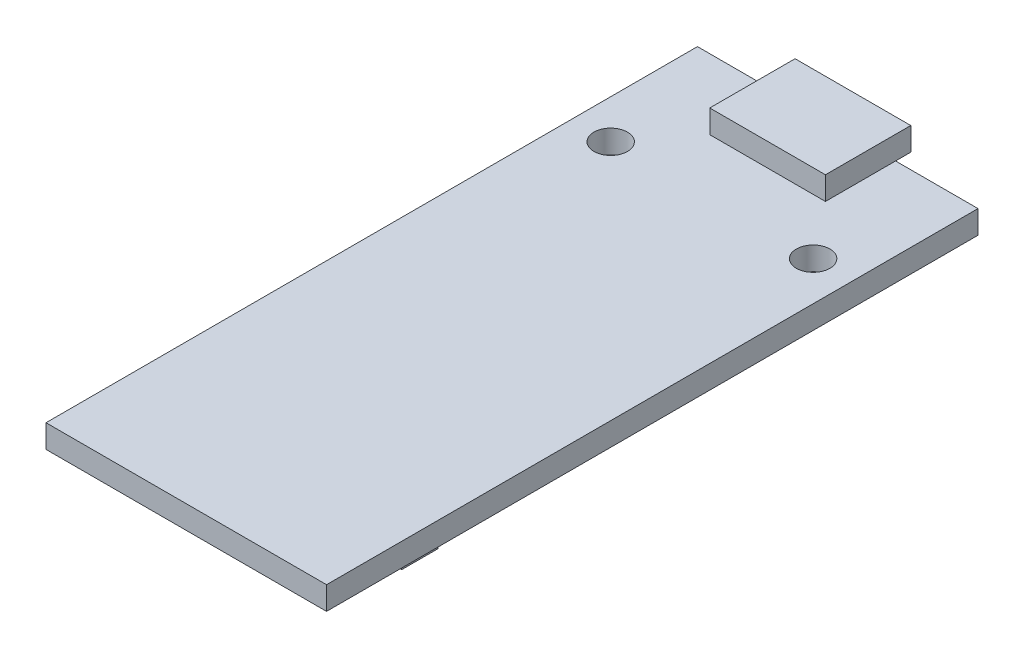
from build123d import *

# Parameters (mm, degrees)
SKETCH1_W           = 19.4
SKETCH1_H           = 45.05
BOSS_EXTRUDE1_DEPTH = 1.6
SKETCH2_W           = 8
SKETCH2_H           = 5.9
BOSS_EXTRUDE2_DEPTH = 1.6
SKETCH3_R           = 1.16
CUT_EXTRUDE3_DEPTH  = 4.2
SKETCH4_W           = 7.25
SKETCH4_H           = 2.5
SKETCH4_W_2         = 16.4
BOSS_EXTRUDE3_DEPTH = 1.6


with BuildPart() as part:
    # Sketch1 → Boss-Extrude1 (new body)
    with BuildSketch(Plane(origin=(0, 0, 0), x_dir=(1, 0, 0), z_dir=(0, 1, 0))):
        with Locations((-9.7, -22.525)):
            Rectangle(SKETCH1_W, SKETCH1_H)
    extrude(amount=BOSS_EXTRUDE1_DEPTH)

    # Sketch2 → Boss-Extrude2 (add)
    with BuildSketch(Plane(origin=(0, 1.6, 0), x_dir=(1, 0, 0), z_dir=(0, 1, 0))):
        with Locations((-9.7, -1.9)):
            Rectangle(SKETCH2_W, SKETCH2_H)
    extrude(amount=BOSS_EXTRUDE2_DEPTH)

    # Sketch3 → Cut-Extrude3 (cut, through all)
    with BuildSketch(Plane(origin=(0, 0, 0), x_dir=(1, 0, 0), z_dir=(0, 1, 0))):
        with Locations((-16.7, -8.7)):
            Circle(SKETCH3_R)
        with Locations((-2.7, -8.7)):
            Circle(SKETCH3_R)
    extrude(amount=CUT_EXTRUDE3_DEPTH, mode=Mode.SUBTRACT)

    # Sketch4 → Boss-Extrude3 (add)
    with BuildSketch(Plane.XZ):
        with Locations((-14.275, 14.12)):
            Rectangle(SKETCH4_W, SKETCH4_H)
        with Locations((-9.7, 37.106432009)):
            Rectangle(SKETCH4_W_2, SKETCH4_H)
    extrude(amount=BOSS_EXTRUDE3_DEPTH)


solid = part.part
